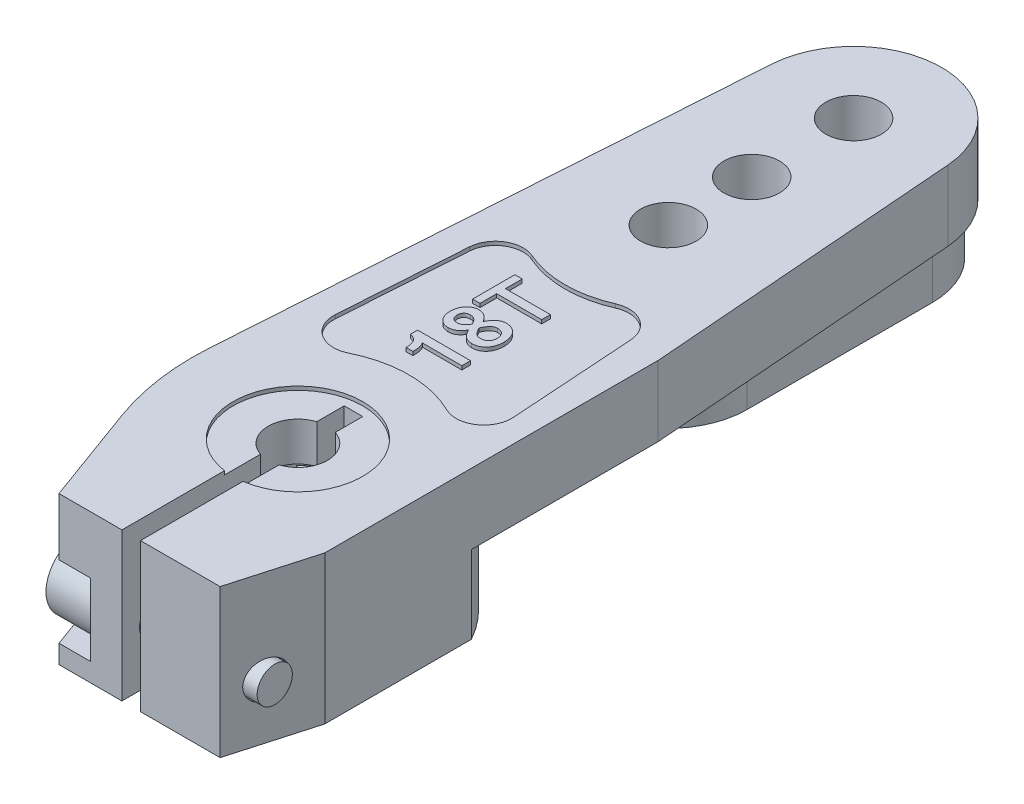
from build123d import *

# Parameters (mm, degrees)
ESQUISSE2_R                  = 6.75
BOSS_EXTRU_1_DEPTH           = 8
ESQUISSE3_R                  = 3.9
ENL_V_MAT_EXTRU_1_DEPTH      = 5.7
BOSS_EXTRU_2_DEPTH           = 4
R_P_TITION_CIRCULAIRE1_COUNT = 18
ESQUISSE5_R                  = 1.5
ESQUISSE5_R_2                = 4.125
BOSS_EXTRU_3_DEPTH           = 8
ESQUISSE6_W                  = 5.995116734
ESQUISSE6_H                  = 5.986651818
ENL_V_MAT_EXTRU_2_DEPTH      = 8
CONG_1_R                     = 13.5
ENL_V_MAT_EXTRU_5_DEPTH      = 1.5
ENL_V_MAT_EXTRU_6_DEPTH      = 2.7
ESQUISSE9_W                  = 2
ESQUISSE9_H                  = 9.04292369
BOSS_EXTRU_4_DEPTH           = 2.7
CONG_2_R                     = 2
ESQUISSE10_R                 = 1.6
ENL_V_MAT_EXTRU_7_DEPTH      = 4
ESQUISSE11_W                 = 1
ESQUISSE11_H                 = 12
ENL_V_MAT_EXTRU_8_DEPTH      = 8
ESQUISSE12_R                 = 3.5
ENL_V_MAT_EXTRU_9_DEPTH      = 0.2
ENL_V_MAT_EXTRU_10_DEPTH     = 5
ESQUISSE14_R                 = 1
ENL_V_MAT_EXTRU_11_DEPTH     = 9
ENL_V_MAT_EXTRU_12_DEPTH     = 0.2
BOSS_EXTRU_5_DEPTH           = 0.2
ESQUISSE17_R                 = 1.85
BOSS_EXTRU_6_DEPTH           = 2.5
ENL_V_MAT_EXTRU_13_DEPTH     = 1.5
ESQUISSE19_R                 = 0.95
BOSS_EXTRU_7_DEPTH           = 8


with BuildPart() as part:
    # Esquisse2 → Boss.-Extru.1 (new body)
    with BuildSketch(Plane(origin=(0, 0, 0), x_dir=(1, 0, 0), z_dir=(0, 1, 0))):
        Circle(ESQUISSE2_R)
    extrude(amount=BOSS_EXTRU_1_DEPTH)

    # Esquisse3 → Enlèv. mat.-Extru.1 (cut)
    with BuildSketch(Plane.XZ):
        Circle(ESQUISSE3_R)
    extrude(amount=-ENL_V_MAT_EXTRU_1_DEPTH, mode=Mode.SUBTRACT)

    # Esquisse4 → Boss.-Extru.2 (add)
    with BuildSketch(Plane.XZ):
        Polygon((-0.4, 3.9), (0.4, 3.9), (0.15, 3.2), (-0.15, 3.2), align=None)
    boss_extru_2 = extrude(amount=-BOSS_EXTRU_2_DEPTH)

    # Répétition circulaire1: Boss.-Extru.2 ×18 about axis
    r_p_tition_circulaire1_axis = Axis((0, 0, 0), (0, 1, 0))
    for i in range(1, R_P_TITION_CIRCULAIRE1_COUNT):
        add(boss_extru_2.rotate(r_p_tition_circulaire1_axis, i * 360 / R_P_TITION_CIRCULAIRE1_COUNT))

    # Esquisse5 → Boss.-Extru.3 (add)
    with BuildSketch(Plane(origin=(0, 8, 0), x_dir=(1, 0, 0), z_dir=(0, 1, 0))):
        with BuildLine():
            Line((-3.9, -9), (4.8, -9))
            Line((4.8, -9), (6.05, -4.6))
            Line((6.05, -4.6), (6.05, 13.4))
            Line((6.05, 13.4), (4.735815077, 30.366818146))
            ThreePointArc((4.735815077, 30.366818146), (-0.025140893, 34.749933466), (-4.73943269, 30.316666667))
            Line((-4.73943269, 30.316666667), (-6.830137326, -0.974135115))
            Line((-6.830137326, -0.974135115), (-3.9, -9))
        make_face()
        with Locations((0, 30)):
            Circle(ESQUISSE5_R, mode=Mode.SUBTRACT)
        with Locations((0, 24.5)):
            Circle(ESQUISSE5_R, mode=Mode.SUBTRACT)
        with Locations((0, 20)):
            Circle(ESQUISSE5_R, mode=Mode.SUBTRACT)
        Circle(ESQUISSE5_R_2, mode=Mode.SUBTRACT)
    extrude(amount=-BOSS_EXTRU_3_DEPTH)

    # Esquisse6 → Enlèv. mat.-Extru.2 (cut)
    with BuildSketch(Plane.XZ):
        with Locations((9.047558367, 0)):
            Rectangle(ESQUISSE6_W, ESQUISSE6_H)
    extrude(amount=-ENL_V_MAT_EXTRU_2_DEPTH, mode=Mode.SUBTRACT)

    # Congé1
    cong_1_edges = [part.edges().sort_by_distance(p)[0] for p in [
        (-6.830137326, 4, 0.974135115),
    ]]
    fillet(cong_1_edges, radius=CONG_1_R)

    # Esquisse7 → Enlèv. mat.-Extru.5 (cut)
    with BuildSketch(Plane.XZ):
        with BuildLine():
            Line((-6.639829266, -1.874135115), (-4.73943269, -30.316666667))
            ThreePointArc((-4.73943269, -30.316666667), (-0.025140893, -34.749933466), (4.735815077, -30.366818146))
            Line((4.735815077, -30.366818146), (6.05, -13.4))
            Line((6.05, -13.4), (6.05, -3.316204926))
            ThreePointArc((6.05, -3.316204926), (-0.779016031, -6.85513305), (-6.639829266, -1.874135115))
        make_face()
    extrude(amount=-ENL_V_MAT_EXTRU_5_DEPTH, mode=Mode.SUBTRACT)

    # Esquisse8 → Enlèv. mat.-Extru.6 (cut)
    with BuildSketch(Plane.XZ.offset(-1.5)):
        with BuildLine():
            Line((-6.639829266, -1.874135115), (-4.73943269, -30.316666667))
            ThreePointArc((-4.73943269, -30.316666667), (-0.025140893, -34.749933466), (4.735815077, -30.366818146))
            Line((4.735815077, -30.366818146), (6.05, -13.4))
            Line((6.05, -13.4), (6.05, -3.316204926))
            ThreePointArc((6.05, -3.316204926), (-0.779016031, -6.85513305), (-6.639829266, -1.874135115))
        make_face()
        with BuildLine():
            Line((-4.25, -30), (-4.25, -20))
            ThreePointArc((-4.25, -20), (0, -15.75), (4.25, -20))
            Line((4.25, -20), (4.25, -30))
            ThreePointArc((4.25, -30), (0, -34.25), (-4.25, -30))
        make_face(mode=Mode.SUBTRACT)
    extrude(amount=-ENL_V_MAT_EXTRU_6_DEPTH, mode=Mode.SUBTRACT)

    # Esquisse9 → Boss.-Extru.4 (add)
    with BuildSketch(Plane.XZ.offset(-1.5)):
        with Locations((0, -11.347860245)):
            Rectangle(ESQUISSE9_W, ESQUISSE9_H)
    extrude(amount=-BOSS_EXTRU_4_DEPTH)

    # Congé2
    cong_2_edges = [part.edges().sort_by_distance(p)[0] for p in [
        (-1, 2.85, -15.86932209),
        (-1, 2.85, -6.8263984),
        (1, 2.85, -6.8263984),
        (1, 2.85, -15.86932209),
    ]]
    fillet(cong_2_edges, radius=CONG_2_R)

    # Esquisse10 → Enlèv. mat.-Extru.7 (cut)
    with BuildSketch(Plane.XZ.offset(-5.7)):
        Circle(ESQUISSE10_R)
    extrude(amount=-ENL_V_MAT_EXTRU_7_DEPTH, mode=Mode.SUBTRACT)

    # Esquisse11 → Enlèv. mat.-Extru.8 (cut)
    with BuildSketch(Plane.XZ.offset(-8)):
        with Locations((0, 3)):
            Rectangle(ESQUISSE11_W, ESQUISSE11_H)
    extrude(amount=ENL_V_MAT_EXTRU_8_DEPTH, mode=Mode.SUBTRACT)

    # Esquisse12 → Enlèv. mat.-Extru.9 (cut)
    with BuildSketch(Plane(origin=(0, 8, 0), x_dir=(1, 0, 0), z_dir=(0, 1, 0))):
        Circle(ESQUISSE12_R)
    extrude(amount=-ENL_V_MAT_EXTRU_9_DEPTH, mode=Mode.SUBTRACT)

    # Esquisse13 → Enlèv. mat.-Extru.10 (cut)
    with BuildSketch(Plane(origin=(-2.2, 0, 0), x_dir=(0, 0, -1), z_dir=(1, 0, 0))):
        with BuildLine():
            Line((-9, 4.9), (-7.05, 4.9))
            ThreePointArc((-7.05, 4.9), (-5.1, 2.95), (-7.05, 1))
            Line((-7.05, 1), (-9, 1))
            Line((-9, 1), (-9, 4.9))
        make_face()
    extrude(amount=-ENL_V_MAT_EXTRU_10_DEPTH, mode=Mode.SUBTRACT)

    # Esquisse14 → Enlèv. mat.-Extru.11 (cut)
    with BuildSketch(Plane.ZY.offset(2.2)):
        with Locations((7.05, 2.95)):
            Circle(ESQUISSE14_R)
    extrude(amount=-ENL_V_MAT_EXTRU_11_DEPTH, mode=Mode.SUBTRACT)

    # Esquisse15 → Enlèv. mat.-Extru.12 (cut)
    with BuildSketch(Plane(origin=(0, 8, 0), x_dir=(1, 0, 0), z_dir=(0, 1, 0))):
        with BuildLine():
            Line((-4.80530764, 6.830740698), (-4.351676574, 13.620068806))
            ThreePointArc((-4.351676574, 13.620068806), (-3.632048344, 14.803118702), (-2.250223577, 14.892741019))
            ThreePointArc((-2.250223577, 14.892741019), (0, 14.418996466), (2.250223577, 14.892741019))
            ThreePointArc((2.250223577, 14.892741019), (3.632048344, 14.803118702), (4.351676574, 13.620068806))
            Line((4.351676574, 13.620068806), (4.80530764, 6.830740698))
            ThreePointArc((4.80530764, 6.830740698), (4.143578703, 5.484592559), (2.646915748, 5.384592559))
            ThreePointArc((2.646915748, 5.384592559), (0, 6), (-2.646915748, 5.384592559))
            ThreePointArc((-2.646915748, 5.384592559), (-4.143578703, 5.484592559), (-4.80530764, 6.830740698))
        make_face()
    extrude(amount=-ENL_V_MAT_EXTRU_12_DEPTH, mode=Mode.SUBTRACT)

    # Esquisse16 → Boss.-Extru.5 (add)
    with BuildSketch(Plane(origin=(0, 7.8, 0), x_dir=(1, 0, 0), z_dir=(0, 1, 0))):
        with BuildLine():
            Line((1, 8.322493904), (1, 7.851635479))
            Line((1, 7.851635479), (-1.138104726, 7.851635479))
            add(Edge.make_bspline(
                [(-1.138104726, 7.851635479), (-1.126290169, 7.838231001), (-1.101092089, 7.809641939), (-1.071485001, 7.7556819), (-1.047259103, 7.690486808), (-1.026262369, 7.614406972), (-1.011031366, 7.526827396), (-0.99992078, 7.427990728), (-0.993243156, 7.317672101), (-0.992488664, 7.240245997), (-0.992093339, 7.199677658)],
                knots=[0, 0, 0, 0, 5.3477e-05, 0.000114056, 0.000183211, 0.000261885, 0.000350468, 0.000449589, 0.000560155, 0.000681852, 0.000681852, 0.000681852, 0.000681852], degree=3))
            Line((-0.992093339, 7.199677658), (-1.354292128, 7.199677658))
            add(Edge.make_bspline(
                [(-1.354292128, 7.199677658), (-1.354482106, 7.225916806), (-1.354851716, 7.276966184), (-1.36161989, 7.351160286), (-1.37064247, 7.421243769), (-1.385139825, 7.486719665), (-1.402258412, 7.548470843), (-1.424623859, 7.605414342), (-1.449716287, 7.658720348), (-1.480270833, 7.706751913), (-1.51337783, 7.751586616), (-1.551827889, 7.790962491), (-1.593167659, 7.827284292), (-1.639236245, 7.858147786), (-1.689062951, 7.885092785), (-1.742731213, 7.907531641), (-1.800505878, 7.925919598), (-1.840720189, 7.934423016), (-1.861370432, 7.938789562)],
                knots=[0, 0, 0, 0, 7.8683e-05, 0.000153082, 0.000223354, 0.000290509, 0.000354099, 0.000415371, 0.000473841, 0.000530531, 0.00058588, 0.000640717, 0.000695288, 0.000750698, 0.00080666, 0.000864995, 0.000924955, 0.000988243, 0.000988243, 0.000988243, 0.000988243], degree=3))
            Line((-1.861370432, 7.938789562), (-1.861370432, 8.322493904))
            Line((-1.861370432, 8.322493904), (1, 8.322493904))
        make_face()
        with BuildLine():
            add(Edge.make_bspline(
                [(-0.490674391, 10.479274505), (-0.480201632, 10.502051637), (-0.459675123, 10.546694601), (-0.424829072, 10.609822897), (-0.389192679, 10.669076818), (-0.351954112, 10.723996675), (-0.312912222, 10.774546165), (-0.272106403, 10.820340532), (-0.230001547, 10.862214546), (-0.185963738, 10.899305753), (-0.140468745, 10.932675277), (-0.092938603, 10.960788718), (-0.04387676, 10.984699437), (0.006541374, 11.004756712), (0.05892136, 11.019817039), (0.112552138, 11.031460337), (0.168122319, 11.037550225), (0.205602198, 11.038501107), (0.224668218, 11.038984821)],
                knots=[0, 0, 0, 0, 7.5184e-05, 0.00014736, 0.000216175, 0.000282573, 0.000346305, 0.000407638, 0.000466465, 0.000524291, 0.000580212, 0.000635535, 0.0006897, 0.000743823, 0.000798085, 0.000853027, 0.000908275, 0.000965479, 0.000965479, 0.000965479, 0.000965479], degree=3))
            add(Edge.make_bspline(
                [(0.224668218, 11.038984821), (0.253390745, 11.038297999), (0.309983932, 11.036944724), (0.392665502, 11.024056365), (0.471698135, 11.003790879), (0.546614741, 10.974700497), (0.618038763, 10.937620323), (0.685461683, 10.892271838), (0.74877411, 10.838312839), (0.807900877, 10.777020149), (0.861299211, 10.708606786), (0.908970417, 10.634934363), (0.947482942, 10.554866319), (0.981044182, 10.470441345), (1.005431447, 10.379757963), (1.023570102, 10.284059454), (1.0345117, 10.182789516), (1.035641169, 10.113518678), (1.036219879, 10.078026159)],
                knots=[0, 0, 0, 0, 8.6113e-05, 0.000169673, 0.000250386, 0.000330471, 0.000410206, 0.000491356, 0.000573674, 0.000659326, 0.000746389, 0.000833677, 0.000922008, 0.001012496, 0.001105861, 0.001203204, 0.001304513, 0.001410963, 0.001410963, 0.001410963, 0.001410963], degree=3))
            add(Edge.make_bspline(
                [(1.036219879, 10.078026159), (1.035646489, 10.044604619), (1.034522493, 9.979089513), (1.023410359, 9.883349552), (1.006052282, 9.792472573), (0.98178642, 9.706352106), (0.949874027, 9.625161299), (0.911415994, 9.548507288), (0.865983093, 9.476635965), (0.813329149, 9.410686051), (0.755359121, 9.35095357), (0.692971393, 9.298184843), (0.625368546, 9.25455907), (0.553949483, 9.217769099), (0.477474712, 9.190445204), (0.397260094, 9.169648922), (0.312367368, 9.157754119), (0.254321625, 9.156296012), (0.224668218, 9.155551119)],
                knots=[0, 0, 0, 0, 0.000100228, 0.000196474, 0.000288707, 0.000377561, 0.000464474, 0.00055002, 0.000634487, 0.000719071, 0.000802717, 0.000883873, 0.000963614, 0.001043593, 0.001124339, 0.001206696, 0.001291854, 0.001380794, 0.001380794, 0.001380794, 0.001380794], degree=3))
            add(Edge.make_bspline(
                [(0.224668218, 9.155551119), (0.205224929, 9.156034208), (0.166992589, 9.156984133), (0.110300086, 9.16308623), (0.0557026, 9.174637564), (0.002586754, 9.18978), (-0.048385733, 9.209850084), (-0.097917625, 9.23359745), (-0.145553867, 9.26187757), (-0.191058013, 9.295226643), (-0.235100449, 9.332317768), (-0.277176209, 9.374214203), (-0.318023314, 9.419827955), (-0.356474263, 9.470569603), (-0.393084827, 9.525508227), (-0.428431537, 9.584418665), (-0.461127331, 9.648186188), (-0.481415257, 9.692542936), (-0.491806262, 9.715261434)],
                knots=[0, 0, 0, 0, 5.8335e-05, 0.000114708, 0.000170758, 0.000225563, 0.000280214, 0.000334887, 0.00039021, 0.000446132, 0.000503957, 0.000562784, 0.000624117, 0.000687505, 0.000753586, 0.000822109, 0.000893488, 0.000968432, 0.000968432, 0.000968432, 0.000968432], degree=3))
            add(Edge.make_bspline(
                [(-0.491806262, 9.715261434), (-0.511972379, 9.679497682), (-0.550889288, 9.610480196), (-0.61992945, 9.518189355), (-0.694268265, 9.439654017), (-0.774710713, 9.375390157), (-0.860941723, 9.325473149), (-0.952976128, 9.290122472), (-1.050622445, 9.267613429), (-1.11798416, 9.265358106), (-1.152253116, 9.264210755)],
                knots=[0, 0, 0, 0, 0.00012307, 0.000237502, 0.000344777, 0.000446684, 0.00054531, 0.00064242, 0.000741556, 0.000844215, 0.000844215, 0.000844215, 0.000844215], degree=3))
            add(Edge.make_bspline(
                [(-1.152253116, 9.264210755), (-1.17776416, 9.26477193), (-1.227704365, 9.26587048), (-1.300662595, 9.277174774), (-1.370238135, 9.294417609), (-1.436173348, 9.319653313), (-1.498706021, 9.351333928), (-1.557586515, 9.390236864), (-1.61270373, 9.436470824), (-1.663911305, 9.489397516), (-1.709978081, 9.548239738), (-1.751071667, 9.611010105), (-1.785376453, 9.678583992), (-1.812683417, 9.750652619), (-1.835215827, 9.82658945), (-1.849923006, 9.907049188), (-1.860183114, 9.991549527), (-1.860968594, 10.049507649), (-1.861370432, 10.07915803)],
                knots=[0, 0, 0, 0, 7.6477e-05, 0.00014971, 0.000220948, 0.000291161, 0.000361017, 0.000430866, 0.000502384, 0.000576427, 0.000651379, 0.000726256, 0.000801173, 0.000878211, 0.000957193, 0.00103844, 0.001123311, 0.001212208, 0.001212208, 0.001212208, 0.001212208], degree=3))
            add(Edge.make_bspline(
                [(-1.861370432, 10.07915803), (-1.860720048, 10.110689732), (-1.859451176, 10.172206659), (-1.849517215, 10.262047522), (-1.834177868, 10.347201811), (-1.81112676, 10.427104172), (-1.783219495, 10.502773165), (-1.747138935, 10.572731635), (-1.705759025, 10.638648764), (-1.657768197, 10.698664116), (-1.605426173, 10.752829335), (-1.549544445, 10.800305744), (-1.490607125, 10.840605972), (-1.428704741, 10.873858479), (-1.363514072, 10.898709245), (-1.295817468, 10.916758465), (-1.225118914, 10.928784917), (-1.176827217, 10.929805727), (-1.152253116, 10.930325184)],
                knots=[0, 0, 0, 0, 9.4572e-05, 0.000184506, 0.000270863, 0.000353809, 0.000433692, 0.000512406, 0.000589493, 0.00066683, 0.000742473, 0.000815153, 0.000886419, 0.000956295, 0.00102545, 0.001095189, 0.001166272, 0.001239922, 0.001239922, 0.001239922, 0.001239922], degree=3))
            add(Edge.make_bspline(
                [(-1.152253116, 10.930325184), (-1.118924904, 10.929162233), (-1.053055282, 10.926863786), (-0.957154132, 10.90422667), (-0.865889378, 10.868955183), (-0.779713188, 10.819017779), (-0.698762936, 10.754772846), (-0.623288579, 10.676292962), (-0.552650361, 10.583886507), (-0.511847715, 10.515013903), (-0.490674391, 10.479274505)],
                knots=[0, 0, 0, 0, 9.9836e-05, 0.000197315, 0.000293898, 0.000392523, 0.000494875, 0.000602934, 0.000718391, 0.000842929, 0.000842929, 0.000842929, 0.000842929], degree=3))
        make_face()
        with BuildLine():
            add(Edge.make_bspline(
                [(-0.666114429, 10.084817386), (-0.681060187, 10.114341686), (-0.709740989, 10.170998604), (-0.759319497, 10.247992957), (-0.813761177, 10.312750089), (-0.871173925, 10.3666753), (-0.933397749, 10.40822733), (-0.999228817, 10.438154772), (-1.069396869, 10.456473837), (-1.117622094, 10.458460014), (-1.142066275, 10.459466759)],
                knots=[0, 0, 0, 0, 9.9239e-05, 0.000190439, 0.000273987, 0.000352487, 0.000425945, 0.000497372, 0.00056861, 0.000641835, 0.000641835, 0.000641835, 0.000641835], degree=3))
            add(Edge.make_bspline(
                [(-1.142066275, 10.459466759), (-1.168787077, 10.458394998), (-1.219933913, 10.456343518), (-1.292040753, 10.437407961), (-1.354944939, 10.405962811), (-1.40728369, 10.361248034), (-1.449493863, 10.305683273), (-1.478040503, 10.238364509), (-1.496753724, 10.161666291), (-1.498339145, 10.106823764), (-1.499171643, 10.078026159)],
                knots=[0, 0, 0, 0, 8.0039e-05, 0.000153205, 0.000221795, 0.000289258, 0.000357963, 0.000429158, 0.000507126, 0.000593334, 0.000593334, 0.000593334, 0.000593334], degree=3))
            add(Edge.make_bspline(
                [(-1.499171643, 10.078026159), (-1.498149733, 10.053213962), (-1.496190234, 10.005636901), (-1.479509222, 9.938194427), (-1.451966294, 9.878394309), (-1.413247277, 9.826526494), (-1.361982096, 9.784603783), (-1.298620592, 9.7552261), (-1.223936641, 9.737608728), (-1.170468589, 9.735950196), (-1.142066275, 9.735069181)],
                knots=[0, 0, 0, 0, 7.4353e-05, 0.000142571, 0.000206882, 0.00027072, 0.000335067, 0.000403414, 0.000478499, 0.000563577, 0.000563577, 0.000563577, 0.000563577], degree=3))
            add(Edge.make_bspline(
                [(-1.142066275, 9.735069181), (-1.116875546, 9.736123398), (-1.06763287, 9.738184176), (-0.996222964, 9.755412601), (-0.929071721, 9.782526936), (-0.867054331, 9.82188687), (-0.80884134, 9.871340116), (-0.756076838, 9.932349399), (-0.707333955, 10.00401244), (-0.680239933, 10.057126369), (-0.666114429, 10.084817386)],
                knots=[0, 0, 0, 0, 7.5482e-05, 0.000147552, 0.000219122, 0.000291828, 0.000366902, 0.000447505, 0.000533054, 0.000626234, 0.000626234, 0.000626234, 0.000626234], degree=3))
        make_face(mode=Mode.SUBTRACT)
        with BuildLine():
            add(Edge.make_bspline(
                [(0.215613248, 10.568126395), (0.189406002, 10.566799362), (0.137899314, 10.564191263), (0.063619532, 10.540703213), (-0.005360547, 10.503518364), (-0.068721477, 10.449919791), (-0.128406686, 10.381089537), (-0.188323334, 10.297587937), (-0.247487586, 10.197196903), (-0.284377009, 10.123729625), (-0.30391564, 10.084817386)],
                knots=[0, 0, 0, 0, 7.8445e-05, 0.000154172, 0.000231408, 0.000312202, 0.000401593, 0.000504158, 0.000620142, 0.000750751, 0.000750751, 0.000750751, 0.000750751], degree=3))
            add(Edge.make_bspline(
                [(-0.30391564, 10.084817386), (-0.285653553, 10.049319014), (-0.250812918, 9.98159478), (-0.194643763, 9.888400411), (-0.136716845, 9.809362341), (-0.078514192, 9.74253517), (-0.015215047, 9.689385157), (0.055727594, 9.652858175), (0.133520887, 9.630371407), (0.187726965, 9.627755365), (0.215613248, 9.626409544)],
                knots=[0, 0, 0, 0, 0.000119746, 0.000228453, 0.000326025, 0.000413396, 0.00049383, 0.0005723, 0.000651126, 0.000734643, 0.000734643, 0.000734643, 0.000734643], degree=3))
            add(Edge.make_bspline(
                [(0.215613248, 9.626409544), (0.233921431, 9.626932307), (0.269494053, 9.627948032), (0.321293004, 9.63326641), (0.369294174, 9.64369079), (0.414253875, 9.657059549), (0.455303448, 9.675256621), (0.493476443, 9.696948696), (0.527789168, 9.7229343), (0.558669561, 9.752655144), (0.585601321, 9.785583556), (0.609642514, 9.820627086), (0.629387165, 9.858368027), (0.645902278, 9.897883799), (0.658424622, 9.939835427), (0.66723295, 9.983793617), (0.673290848, 10.030132284), (0.673773419, 10.061782325), (0.67402109, 10.078026159)],
                knots=[0, 0, 0, 0, 5.4942e-05, 0.000106753, 0.000155924, 0.000202109, 0.000247218, 0.000290318, 0.000333556, 0.000375982, 0.000418589, 0.00046097, 0.000503249, 0.000546129, 0.000589278, 0.00063434, 0.000680529, 0.000729229, 0.000729229, 0.000729229, 0.000729229], degree=3))
            add(Edge.make_bspline(
                [(0.67402109, 10.078026159), (0.673753167, 10.096151528), (0.67322987, 10.13155323), (0.667457648, 10.183239268), (0.657877001, 10.232297573), (0.64432802, 10.278479752), (0.627396797, 10.322021561), (0.606127857, 10.362482585), (0.581497432, 10.40053252), (0.552356088, 10.434833074), (0.520755425, 10.466434489), (0.485467383, 10.493291702), (0.447910612, 10.517146323), (0.406778303, 10.535512555), (0.363089497, 10.550504203), (0.316324868, 10.560390714), (0.26691341, 10.566800411), (0.232989696, 10.567677257), (0.215613248, 10.568126395)],
                knots=[0, 0, 0, 0, 5.4356e-05, 0.000106167, 0.000155779, 0.000204132, 0.000250373, 0.000295683, 0.000341046, 0.000386045, 0.000430466, 0.000474841, 0.000518813, 0.000563636, 0.00060963, 0.000657142, 0.00070677, 0.000758886, 0.000758886, 0.000758886, 0.000758886], degree=3))
        make_face(mode=Mode.SUBTRACT)
        Polygon((-1.426731886, 13.538156464), (-1.426731886, 12.632659492), (1, 12.632659492), (1, 12.161801066), (-1.426731886, 12.161801066), (-1.426731886, 11.256304094), (-1.825150553, 11.256304094), (-1.825150553, 13.538156464), align=None)
    extrude(amount=BOSS_EXTRU_5_DEPTH)

    # Esquisse17 → Boss.-Extru.6 (add)
    with BuildSketch(Plane.ZY.offset(2.2)):
        with Locations((7.05, 2.95)):
            Circle(ESQUISSE17_R)
    extrude(amount=BOSS_EXTRU_6_DEPTH)

    # Esquisse18 → Enlèv. mat.-Extru.13 (cut)
    with BuildSketch(Plane.ZY.offset(4.7)):
        Polygon((7.627350269, 1.95), (8.204700538, 2.95), (7.627350269, 3.95), (6.472649731, 3.95), (5.895299462, 2.95), (6.472649731, 1.95), align=None)
    extrude(amount=-ENL_V_MAT_EXTRU_13_DEPTH, mode=Mode.SUBTRACT)

    # Esquisse19 → Boss.-Extru.7 (add)
    with BuildSketch(Plane(origin=(-2.2, 0, 0), x_dir=(0, 0, -1), z_dir=(1, 0, 0))):
        with Locations((-7.05, 2.95)):
            Circle(ESQUISSE19_R)
    extrude(amount=BOSS_EXTRU_7_DEPTH)


solid = part.part
